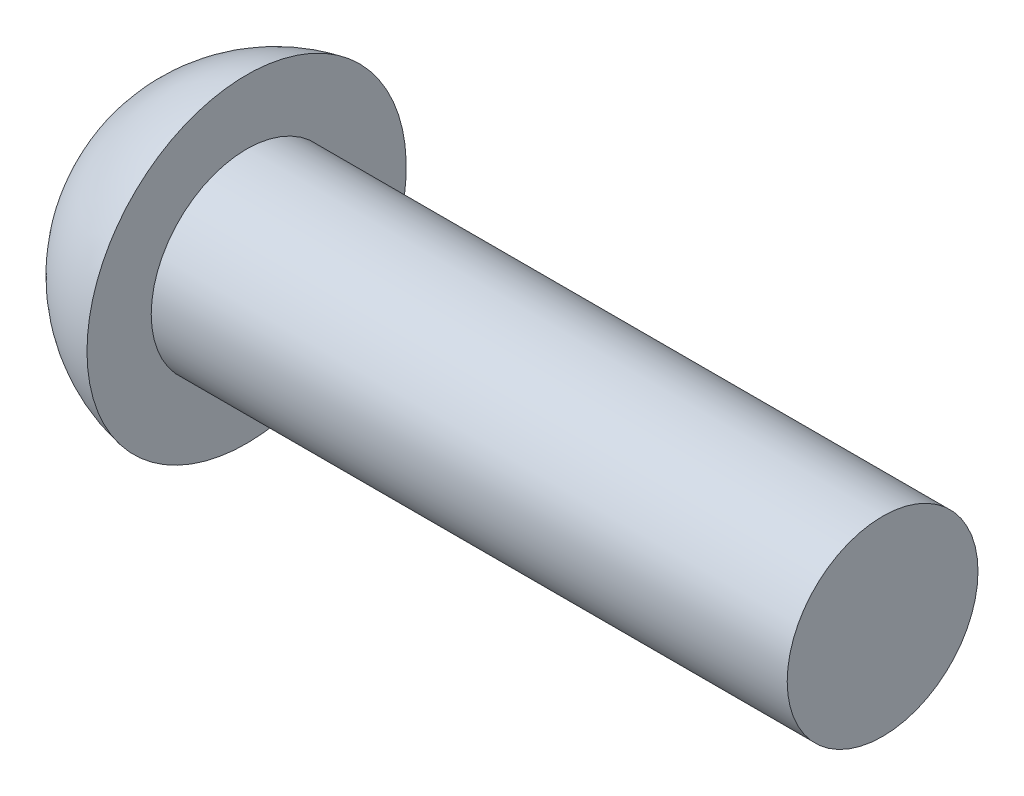
from build123d import *

# Parameters (mm, degrees)
SKETCH3_W    = 0.82
SKETCH3_H    = 7
SKETCH4_W    = 0.82
SKETCH4_H    = 3.809077818
RECPAT_COUNT = 2
RECPAT_ANGLE = 90


with BuildPart() as part:
    # BodySke → Base-Revolve (revolve)
    with BuildSketch(Plane.XY):
        with BuildLine():
            Line((4.2, 3), (4.2, 5.019960159))
            ThreePointArc((4.2, 5.019960159), (1.188478557, 3.272613634), (0, 0))
            Line((0, 0), (24.2, 0))
            Line((24.2, 0), (24.2, 3))
            Line((24.2, 3), (4.2, 3))
        make_face()
    revolve(axis=Axis((-25.4, 0, 0), (1, 0, 0)))

    # Sketch3 → Recess section 0
    with BuildSketch(Plane(origin=(0, 0, 0), x_dir=(0, 0, -1), z_dir=(1, 0, 0))):
        Rectangle(SKETCH3_W, SKETCH3_H)
    # Sketch4 → Recess section 1
    with BuildSketch(Plane(origin=(3.2, 0, 0), x_dir=(0, 0, -1), z_dir=(1, 0, 0))):
        Rectangle(SKETCH4_W, SKETCH4_H)
    recess = loft(mode=Mode.SUBTRACT)

    # RecPat: Recess ×2 about axis
    recpat_axis = Axis((0, 0, 0), (1, 0, 0))
    for i in range(1, RECPAT_COUNT):
        add(recess.rotate(recpat_axis, i * RECPAT_ANGLE / (RECPAT_COUNT - 1)), mode=Mode.SUBTRACT)

    # RecCorSke → RecessCore (revolve, cut)
    with BuildSketch(Plane.XY):
        Polygon((0, 0), (0, 1.504265798), (3.2, 1.2805), (3.616059671, 0), align=None)
    revolve(axis=Axis((-3.175, 0, 0), (1, 0, 0)), mode=Mode.SUBTRACT)


solid = part.part
